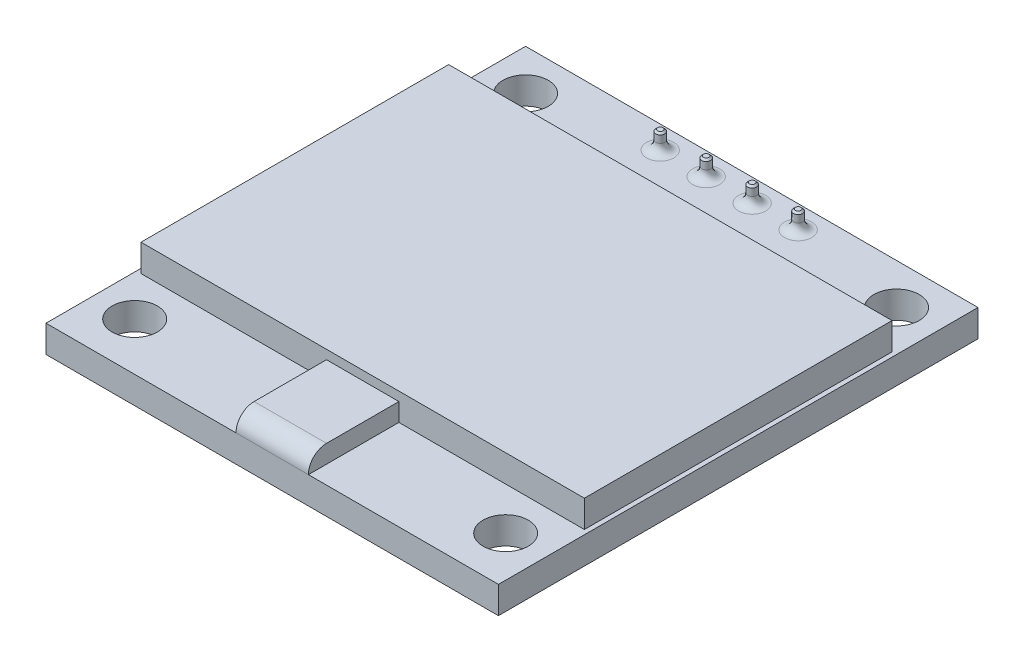
from build123d import *

# Parameters (mm, degrees)
SKETCH1_W                  = 25
SKETCH1_H                  = 26.5
BOSS_EXTRUDE1_DEPTH        = 1.5
SKETCH2_W                  = 24.5
SKETCH2_H                  = 17
BOSS_EXTRUDE2_DEPTH        = 1.5
SKETCH3_R                  = 1.25
CUT_EXTRUDE1_DEPTH         = 7.5
SKETCH4_R                  = 1.25
CUT_EXTRUDE2_DEPTH         = 7.5
SKETCH5_W                  = 4
SKETCH5_H                  = 5
BOSS_EXTRUDE3_DEPTH        = 1
FILLET1_R                  = 1
BOSS_EXTRUDE4_START        = -9.6
SKETCH6_R                  = 0.25
BOSS_EXTRUDE4_DEPTH        = 10.6
CHAMFER1_SIZE              = 0.1
FILLET2_R                  = 0.5
LPATTERN1_COUNT            = 4
LPATTERN1_PITCH            = 2.54
CHAMFER1_OF_LPATTERN1_SIZE = 0.1
FILLET2_OF_LPATTERN1_R     = 0.5
SKETCH7_W                  = 10
SKETCH7_H                  = 2.5
BOSS_EXTRUDE5_DEPTH        = 2.5
FILLET3_R                  = 0.75


with BuildPart() as part:
    # Sketch1 → Boss-Extrude1 (new body)
    with BuildSketch(Plane(origin=(0, 0, 0), x_dir=(1, 0, 0), z_dir=(0, 1, 0))):
        Rectangle(SKETCH1_W, SKETCH1_H)
    extrude(amount=BOSS_EXTRUDE1_DEPTH)

    # Sketch2 → Boss-Extrude2 (add)
    with BuildSketch(Plane(origin=(0, 1.5, 0), x_dir=(1, 0, 0), z_dir=(0, 1, 0))):
        with Locations((0, 0.25)):
            Rectangle(SKETCH2_W, SKETCH2_H)
    extrude(amount=BOSS_EXTRUDE2_DEPTH)

    # Sketch3 → Cut-Extrude1 (cut)
    with BuildSketch(Plane(origin=(0, 1.5, 0), x_dir=(1, 0, 0), z_dir=(0, 1, 0))):
        with Locations((-10.25, -10.6)):
            Circle(SKETCH3_R)
    cut_extrude1 = extrude(amount=-CUT_EXTRUDE1_DEPTH, mode=Mode.SUBTRACT)

    # Mirror1: Cut-Extrude1 across plane
    add(cut_extrude1.mirror(Plane(origin=(0, 0, 0), x_dir=(0, 0, 1), z_dir=(1, 0, 0))), mode=Mode.SUBTRACT)

    # Sketch4 → Cut-Extrude2 (cut)
    with BuildSketch(Plane(origin=(0, 1.5, 0), x_dir=(1, 0, 0), z_dir=(0, 1, 0))):
        with Locations((-10.25, 11)):
            Circle(SKETCH4_R)
    cut_extrude2 = extrude(amount=-CUT_EXTRUDE2_DEPTH, mode=Mode.SUBTRACT)

    # Mirror2: Cut-Extrude2 across plane
    add(cut_extrude2.mirror(Plane(origin=(0, 0, 0), x_dir=(0, 0, 1), z_dir=(1, 0, 0))), mode=Mode.SUBTRACT)

    # Sketch5 → Boss-Extrude3 (add)
    with BuildSketch(Plane(origin=(0, 1.5, 0), x_dir=(1, 0, 0), z_dir=(0, 1, 0))):
        with Locations((0, -10.75)):
            Rectangle(SKETCH5_W, SKETCH5_H)
    extrude(amount=BOSS_EXTRUDE3_DEPTH)

    # Fillet1
    fillet1_edges = [part.edges().sort_by_distance(p)[0] for p in [
        (0, 2.5, 13.25),
    ]]
    fillet(fillet1_edges, radius=FILLET1_R)

    # Sketch6 → Boss-Extrude4 (add)
    with BuildSketch(Plane(origin=(0, 1.5, 0), x_dir=(1, 0, 0), z_dir=(0, 1, 0)).offset(BOSS_EXTRUDE4_START)):
        with Locations((-3.81, 12)):
            Circle(SKETCH6_R)
    boss_extrude4 = extrude(amount=BOSS_EXTRUDE4_DEPTH)

    # Chamfer1
    chamfer1_edges = [part.edges().sort_by_distance(p)[0] for p in [
        (-4.06, 2.5, -12),
    ]]
    chamfer(chamfer1_edges, length=CHAMFER1_SIZE)

    # Fillet2
    fillet2_edges = [part.edges().sort_by_distance(p)[0] for p in [
        (-4.06, 1.5, -12),
    ]]
    fillet(fillet2_edges, radius=FILLET2_R)

    # LPattern1: Boss-Extrude4 ×4
    with Locations(*[(i * LPATTERN1_PITCH, 0, 0) for i in range(1, LPATTERN1_COUNT)]):
        add(boss_extrude4)

    # Chamfer1 of LPattern1
    chamfer1_of_lpattern1_edges = [part.edges().sort_by_distance(p)[0] for p in [
        (-1.52, 2.5, -12),
        (1.02, 2.5, -12),
        (3.56, 2.5, -12),
    ]]
    chamfer(chamfer1_of_lpattern1_edges, length=CHAMFER1_OF_LPATTERN1_SIZE)

    # Fillet2 of LPattern1
    fillet2_of_lpattern1_edges = [part.edges().sort_by_distance(p)[0] for p in [
        (-1.52, 1.5, -12),
        (1.02, 1.5, -12),
        (3.56, 1.5, -12),
    ]]
    fillet(fillet2_of_lpattern1_edges, radius=FILLET2_OF_LPATTERN1_R)

    # Sketch7 → Boss-Extrude5 (add)
    with BuildSketch(Plane.XZ):
        with Locations((0, -12)):
            Rectangle(SKETCH7_W, SKETCH7_H)
    extrude(amount=BOSS_EXTRUDE5_DEPTH)

    # Fillet3
    fillet3_edges = [part.edges().sort_by_distance(p)[0] for p in [
        (-5, -1.25, -10.75),
        (-5, -1.25, -13.25),
        (5, -1.25, -13.25),
        (5, -1.25, -10.75),
    ]]
    fillet(fillet3_edges, radius=FILLET3_R)


solid = part.part
